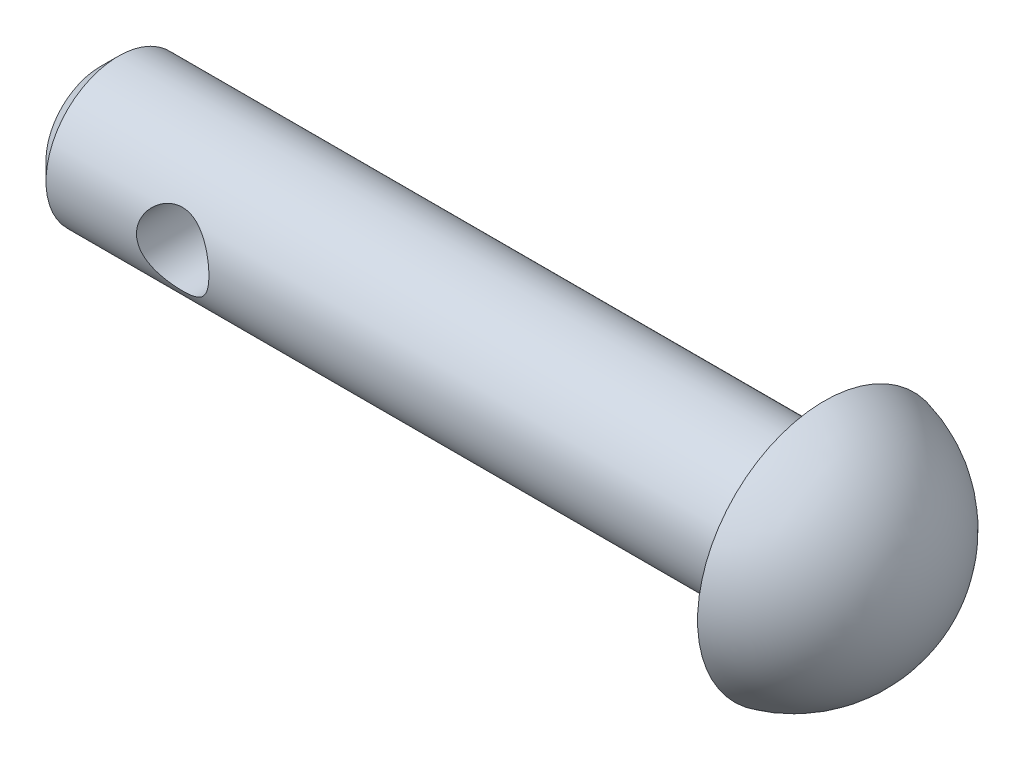
from build123d import *

# Parameters (mm, degrees)
SKETCH1_R               = 2
BOSS_EXTRUDE1_DEPTH     = 20
SKETCH2_R               = 1
CUT_EXTRUDE1_DEPTH      = 3
CUT_EXTRUDE1_DEPTH_BACK = 3
CHAMFER1_SIZE           = 0.5


with BuildPart() as part:
    # Sketch1 → Boss-Extrude1 (new body)
    with BuildSketch(Plane(origin=(0, 0, 0), x_dir=(0, 0, -1), z_dir=(1, 0, 0))):
        Circle(SKETCH1_R)
    extrude(amount=-BOSS_EXTRUDE1_DEPTH)

    # Sketch2 → Cut-Extrude1 (cut, two sides)
    with BuildSketch(Plane.XY) as cut_extrude1_sk:
        with Locations((-16, 0)):
            Circle(SKETCH2_R)
    extrude(amount=CUT_EXTRUDE1_DEPTH, mode=Mode.SUBTRACT)
    extrude(cut_extrude1_sk.sketch, amount=-CUT_EXTRUDE1_DEPTH_BACK, mode=Mode.SUBTRACT)

    # Chamfer1
    chamfer1_edges = [part.edges().sort_by_distance(p)[0] for p in [
        (-20, 0, 2),
    ]]
    chamfer(chamfer1_edges, length=CHAMFER1_SIZE)

    # Sketch3 → Revolve1 (revolve)
    with BuildSketch(Plane(origin=(0, 0, 0), x_dir=(1, 0, 0), z_dir=(0, 1, 0))):
        with BuildLine():
            Line((2.757385023, 0), (0, 0))
            Line((0, 0), (0, 3.5))
            ThreePointArc((0, 3.5), (1.985229955, 2.227844932), (2.757385023, 0))
        make_face()
    revolve(axis=Axis((3.35333719, 0, 0), (-1, 0, 0)))


solid = part.part
